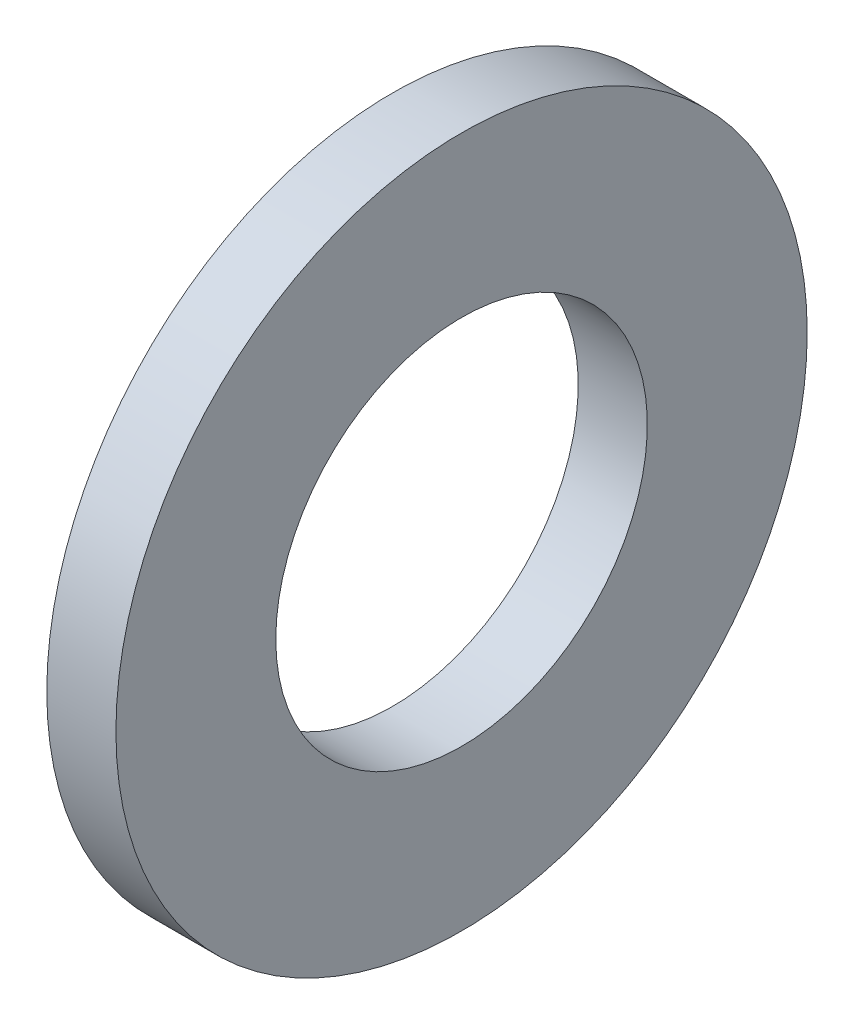
from build123d import *

# Parameters (mm, degrees)
ESQUISSE1_W = 0.8
ESQUISSE1_H = 1.85


with BuildPart() as part:
    # Esquisse1 → Base-Révolution (revolve)
    with BuildSketch(Plane(origin=(0, 0, 0), x_dir=(1, 0, 0), z_dir=(0, 1, 0))):
        with Locations((0.4, 3.075)):
            Rectangle(ESQUISSE1_W, ESQUISSE1_H)
    revolve(axis=Axis((0, 0, 0), (1, 0, 0)))


solid = part.part
